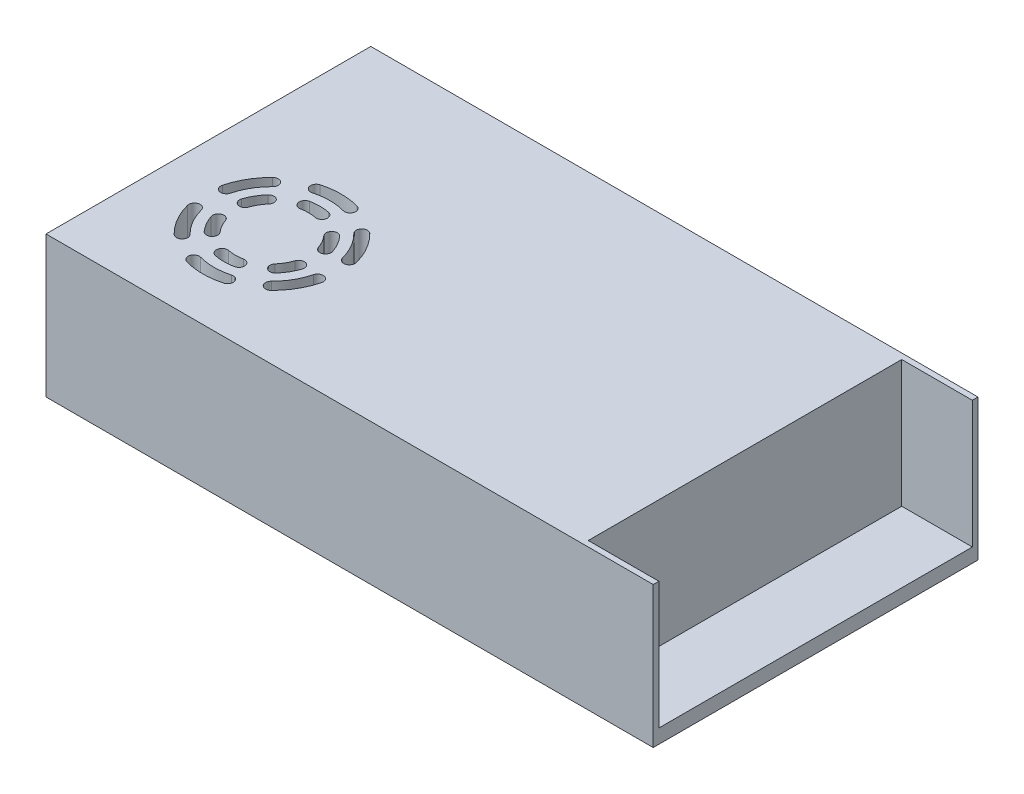
from build123d import *

# Parameters (mm, degrees)
SKETCH_1_W          = 215
SKETCH_1_H          = 115
EXTRUDE_1_DEPTH     = 50
SKETCH_2_W          = 25
SKETCH_2_H          = 111
CUT_EXTRUDE_1_DEPTH = 45
CUT_EXTRUDE_3_DEPTH = 15


with BuildPart() as part:
    # Эскиз1 → Бобышка-Вытянуть1 (new body)
    with BuildSketch(Plane(origin=(0, 0, 0), x_dir=(1, 0, 0), z_dir=(0, 1, 0))):
        with Locations((107.5, 57.5)):
            Rectangle(SKETCH_1_W, SKETCH_1_H)
    extrude(amount=EXTRUDE_1_DEPTH)

    # Эскиз2 → Вырез-Вытянуть1 (cut)
    with BuildSketch(Plane(origin=(0, 50, 0), x_dir=(1, 0, 0), z_dir=(0, 1, 0))):
        with Locations((202.5, 57.5)):
            Rectangle(SKETCH_2_W, SKETCH_2_H)
    extrude(amount=-CUT_EXTRUDE_1_DEPTH, mode=Mode.SUBTRACT)

    # Эскиз3 → Вырез-Вытянуть3 (cut)
    with BuildSketch(Plane(origin=(0, 50, 0), x_dir=(1, 0, 0), z_dir=(0, 1, 0))):
        with BuildLine():
            ThreePointArc((36.6, 23.343469749), (40, 23), (43.4, 23.343469749))
            ThreePointArc((43.4, 23.343469749), (44.959591794, 25.703061543), (42.6, 27.262653338))
            ThreePointArc((42.6, 27.262653338), (40, 27), (37.4, 27.262653338))
            ThreePointArc((37.4, 27.262653338), (35.040408206, 25.703061543), (36.6, 23.343469749))
        make_face()
        with BuildLine():
            ThreePointArc((23.875021664, 34.616221247), (25.277568136, 31.5), (27.275021664, 28.727248502))
            ThreePointArc((27.275021664, 28.727248502), (30.098283997, 28.556398285), (30.269134213, 31.379660619))
            ThreePointArc((30.269134213, 31.379660619), (28.741669751, 33.5), (27.669134213, 35.882992719))
            ThreePointArc((27.669134213, 35.882992719), (25.138692203, 37.146663258), (23.875021664, 34.616221247))
        make_face()
        with BuildLine():
            ThreePointArc((27.275021664, 51.272751498), (25.277568136, 48.5), (23.875021664, 45.383778753))
            ThreePointArc((23.875021664, 45.383778753), (25.138692203, 42.853336742), (27.669134213, 44.117007281))
            ThreePointArc((27.669134213, 44.117007281), (28.741669751, 46.5), (30.269134213, 48.620339381))
            ThreePointArc((30.269134213, 48.620339381), (30.098283997, 51.443601715), (27.275021664, 51.272751498))
        make_face()
        with BuildLine():
            ThreePointArc((43.4, 56.656530251), (40, 57), (36.6, 56.656530251))
            ThreePointArc((36.6, 56.656530251), (35.040408206, 54.296938457), (37.4, 52.737346662))
            ThreePointArc((37.4, 52.737346662), (40, 53), (42.6, 52.737346662))
            ThreePointArc((42.6, 52.737346662), (44.959591794, 54.296938457), (43.4, 56.656530251))
        make_face()
        with BuildLine():
            ThreePointArc((56.124978336, 45.383778753), (54.722431864, 48.5), (52.724978336, 51.272751498))
            ThreePointArc((52.724978336, 51.272751498), (49.901716003, 51.443601715), (49.730865787, 48.620339381))
            ThreePointArc((49.730865787, 48.620339381), (51.258330249, 46.5), (52.330865787, 44.117007281))
            ThreePointArc((52.330865787, 44.117007281), (54.861307797, 42.853336742), (56.124978336, 45.383778753))
        make_face()
        with BuildLine():
            ThreePointArc((52.724978336, 28.727248502), (54.722431864, 31.5), (56.124978336, 34.616221247))
            ThreePointArc((56.124978336, 34.616221247), (54.861307797, 37.146663258), (52.330865787, 35.882992719))
            ThreePointArc((52.330865787, 35.882992719), (51.258330249, 33.5), (49.730865787, 31.379660619))
            ThreePointArc((49.730865787, 31.379660619), (49.901716003, 28.556398285), (52.724978336, 28.727248502))
        make_face()
        with BuildLine():
            ThreePointArc((33.466666667, 16.387173918), (40, 15.5), (46.533333333, 16.387173918))
            ThreePointArc((46.533333333, 16.387173918), (47.927577639, 18.848084891), (45.466666667, 20.242329197))
            ThreePointArc((45.466666667, 20.242329197), (40, 19.5), (34.533333333, 20.242329197))
            ThreePointArc((34.533333333, 20.242329197), (32.072422361, 18.848084891), (33.466666667, 16.387173918))
        make_face()
        with BuildLine():
            ThreePointArc((16.284026092, 33.851619597), (18.782377607, 27.75), (22.817359425, 22.535554321))
            ThreePointArc((22.817359425, 22.535554321), (25.645692997, 22.558558819), (25.622688498, 25.386892391))
            ThreePointArc((25.622688498, 25.386892391), (22.246479222, 29.75), (20.156021832, 34.855436806))
            ThreePointArc((20.156021832, 34.855436806), (17.718115357, 36.289526072), (16.284026092, 33.851619597))
        make_face()
        with BuildLine():
            ThreePointArc((22.817359425, 57.464445679), (18.782377607, 52.25), (16.284026092, 46.148380403))
            ThreePointArc((16.284026092, 46.148380403), (17.718115357, 43.710473928), (20.156021832, 45.144563194))
            ThreePointArc((20.156021832, 45.144563194), (22.246479222, 50.25), (25.622688498, 54.613107609))
            ThreePointArc((25.622688498, 54.613107609), (25.645692997, 57.441441181), (22.817359425, 57.464445679))
        make_face()
        with BuildLine():
            ThreePointArc((46.533333333, 63.612826082), (40, 64.5), (33.466666667, 63.612826082))
            ThreePointArc((33.466666667, 63.612826082), (32.072422361, 61.151915109), (34.533333333, 59.757670803))
            ThreePointArc((34.533333333, 59.757670803), (40, 60.5), (45.466666667, 59.757670803))
            ThreePointArc((45.466666667, 59.757670803), (47.927577639, 61.151915109), (46.533333333, 63.612826082))
        make_face()
        with BuildLine():
            ThreePointArc((63.715973908, 46.148380403), (61.217622393, 52.25), (57.182640575, 57.464445679))
            ThreePointArc((57.182640575, 57.464445679), (54.354307003, 57.441441181), (54.377311502, 54.613107609))
            ThreePointArc((54.377311502, 54.613107609), (57.753520778, 50.25), (59.843978168, 45.144563194))
            ThreePointArc((59.843978168, 45.144563194), (62.281884643, 43.710473928), (63.715973908, 46.148380403))
        make_face()
        with BuildLine():
            ThreePointArc((57.182640575, 22.535554321), (61.217622393, 27.75), (63.715973908, 33.851619597))
            ThreePointArc((63.715973908, 33.851619597), (62.281884643, 36.289526072), (59.843978168, 34.855436806))
            ThreePointArc((59.843978168, 34.855436806), (57.753520778, 29.75), (54.377311502, 25.386892391))
            ThreePointArc((54.377311502, 25.386892391), (54.354307003, 22.558558819), (57.182640575, 22.535554321))
        make_face()
    extrude(amount=-CUT_EXTRUDE_3_DEPTH, mode=Mode.SUBTRACT)


solid = part.part
